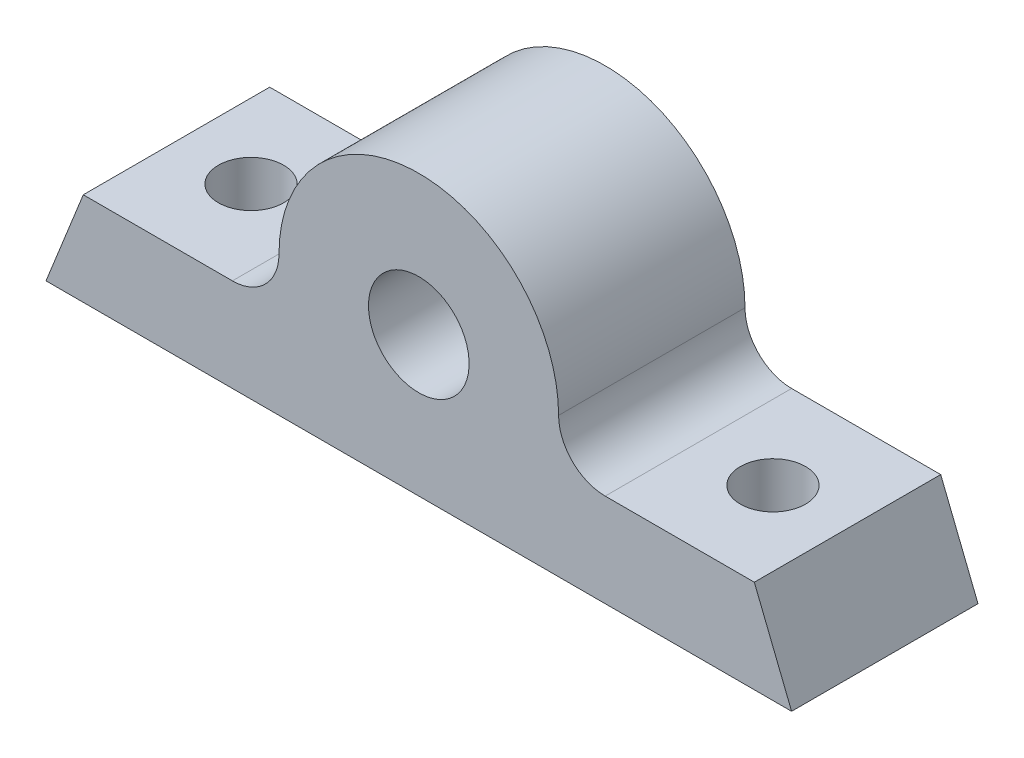
from build123d import *

# Parameters (mm, degrees)
SKETCH1_R           = 1.5
BOSS_EXTRUDE1_DEPTH = 10
SKETCH3_R           = 1.75
CUT_EXTRUDE1_DEPTH  = 6


with BuildPart() as part:
    # Sketch1 → Boss-Extrude1 (new body)
    with BuildSketch(Plane.XY):
        with BuildLine():
            Line((-10, -2.5), (-18, -2.5))
            Line((-18, -2.5), (-20, -7.5))
            Line((-20, -7.5), (20, -7.5))
            Line((20, -7.5), (18, -2.5))
            Line((18, -2.5), (10, -2.5))
            ThreePointArc((10, -2.5), (8.232233047, -1.767766953), (7.5, 0))
            ThreePointArc((7.5, 0), (0, 7.5), (-7.5, 0))
            ThreePointArc((-7.5, 0), (-8.232233047, -1.767766953), (-10, -2.5))
        make_face()
        Circle(SKETCH1_R, mode=Mode.SUBTRACT)
    extrude(amount=BOSS_EXTRUDE1_DEPTH)

    # Sketch2 → Cut-Revolve1 (revolve, cut)
    with BuildSketch(Plane(origin=(0, 0, 0), x_dir=(1, 0, 0), z_dir=(0, 1, 0))):
        Polygon((0, 0), (0, -5), (4, 0), align=None)
        Polygon((2.7, -5), (1.5, -5), (1.5, -3.125), (0, -5), (0, -10), (2.7, -10), align=None)
    revolve(axis=Axis((0, 0, 0), (0, 0, 1)), mode=Mode.SUBTRACT)

    # Sketch3 → Cut-Extrude1 (cut, through all)
    with BuildSketch(Plane(origin=(0, -2.5, 0), x_dir=(1, 0, 0), z_dir=(0, 1, 0))):
        with Locations((-14, -5)):
            Circle(SKETCH3_R)
        with Locations((14, -5)):
            Circle(SKETCH3_R)
    extrude(amount=-CUT_EXTRUDE1_DEPTH, mode=Mode.SUBTRACT)


solid = part.part
